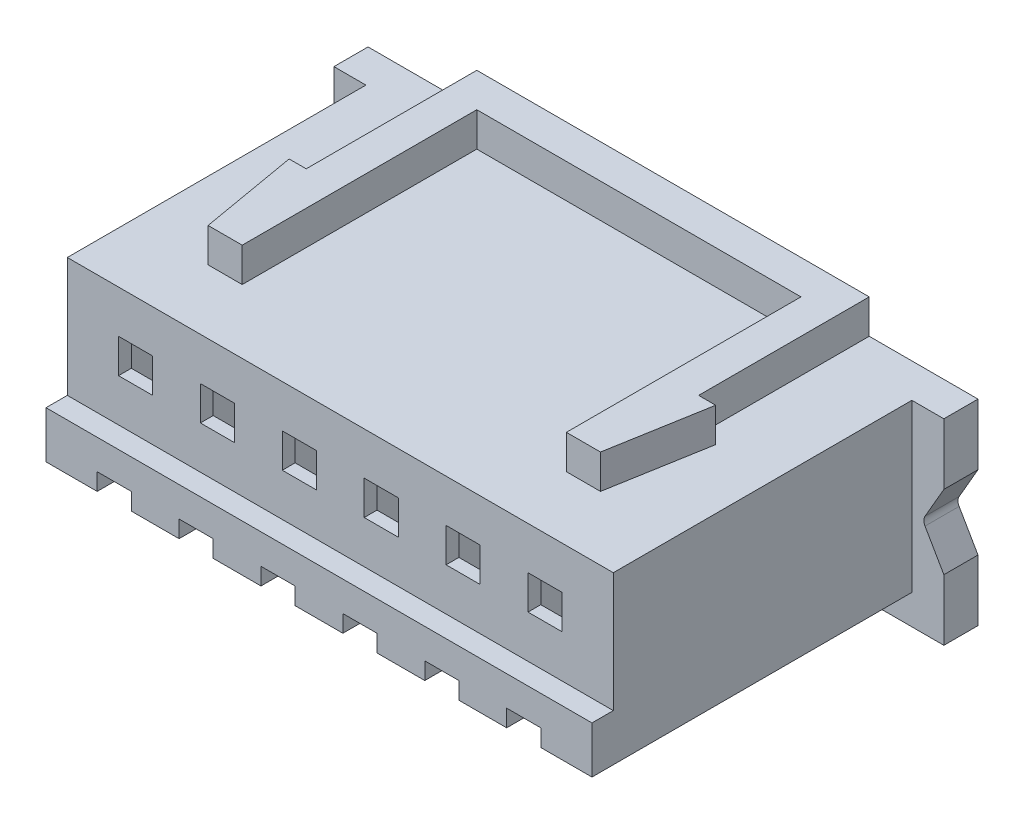
from build123d import *

# Parameters (mm, degrees)
SKETCH1_W           = 12.8
SKETCH1_H           = 4.3
BOSS_EXTRUDE1_DEPTH = 7
SKETCH2_W           = 14.3
SKETCH2_H           = 4.6
BOSS_EXTRUDE2_DEPTH = 0.8
CUT_EXTRUDE1_DEPTH  = 1
FILLET1_R           = 0.2
SKETCH4_W           = 12.8
SKETCH4_H           = 1.5
BOSS_EXTRUDE3_DEPTH = 0.5
SKETCH5_W           = 0.8
SKETCH5_H           = 0.8
CUT_EXTRUDE2_DEPTH  = 3.2
SKETCH6_W           = 0.8
SKETCH6_H           = 0.8
CUT_EXTRUDE3_DEPTH  = 10
BOSS_EXTRUDE4_DEPTH = 0.8
CUT_EXTRUDE4_DEPTH  = 7.5
CUT_EXTRUDE5_DEPTH  = 0.4
BOSS_EXTRUDE5_DEPTH = 0.1


with BuildPart() as part:
    # Sketch1 → Boss-Extrude1 (new body)
    with BuildSketch(Plane.XY):
        Rectangle(SKETCH1_W, SKETCH1_H)
    extrude(amount=BOSS_EXTRUDE1_DEPTH)

    # Sketch2 → Boss-Extrude2 (add)
    with BuildSketch(Plane(origin=(0, 0, 0), x_dir=(-1, 0, 0), z_dir=(0, 0, -1))):
        with Locations((0, -0.15)):
            Rectangle(SKETCH2_W, SKETCH2_H)
    extrude(amount=BOSS_EXTRUDE2_DEPTH)

    # Sketch3 → Cut-Extrude1 (cut)
    with BuildSketch(Plane.XY):
        Polygon((6.65, -0.15), (7.15, -1.016025404), (7.15, 0.716025404), align=None)
    extrude(amount=-CUT_EXTRUDE1_DEPTH, mode=Mode.SUBTRACT)

    # Fillet1
    fillet1_edges = [part.edges().sort_by_distance(p)[0] for p in [
        (6.65, -0.15, -0.4),
    ]]
    fillet(fillet1_edges, radius=FILLET1_R)

    # Sketch4 → Boss-Extrude3 (add)
    with BuildSketch(Plane.XY.offset(7)):
        with Locations((0, -1.4)):
            Rectangle(SKETCH4_W, SKETCH4_H)
    extrude(amount=BOSS_EXTRUDE3_DEPTH)

    # Sketch5 → Cut-Extrude2 (cut)
    with BuildSketch(Plane.XY.offset(7.5)):
        with Locations((2.88, -1.75)):
            Rectangle(SKETCH5_W, SKETCH5_H)
        with Locations((0.96, -1.75)):
            Rectangle(SKETCH5_W, SKETCH5_H)
        with Locations((-0.96, -1.75)):
            Rectangle(SKETCH5_W, SKETCH5_H)
        with Locations((4.8, -1.75)):
            Rectangle(SKETCH5_W, SKETCH5_H)
        with Locations((-2.88, -1.75)):
            Rectangle(SKETCH5_W, SKETCH5_H)
        with Locations((-4.8, -1.75)):
            Rectangle(SKETCH5_W, SKETCH5_H)
    extrude(amount=-CUT_EXTRUDE2_DEPTH, mode=Mode.SUBTRACT)

    # Sketch6 → Cut-Extrude3 (cut)
    with BuildSketch(Plane.XY.offset(7)):
        with Locations((-4.8, 0.75)):
            Rectangle(SKETCH6_W, SKETCH6_H)
        with Locations((-2.88, 0.75)):
            Rectangle(SKETCH6_W, SKETCH6_H)
        with Locations((-0.96, 0.75)):
            Rectangle(SKETCH6_W, SKETCH6_H)
        with Locations((0.96, 0.75)):
            Rectangle(SKETCH6_W, SKETCH6_H)
        with Locations((2.88, 0.75)):
            Rectangle(SKETCH6_W, SKETCH6_H)
        with Locations((4.8, 0.75)):
            Rectangle(SKETCH6_W, SKETCH6_H)
    extrude(amount=-CUT_EXTRUDE3_DEPTH, mode=Mode.SUBTRACT)

    # Sketch7 → Boss-Extrude4 (add)
    with BuildSketch(Plane(origin=(0, 2.15, 0), x_dir=(1, 0, 0), z_dir=(0, 1, 0))):
        Polygon((-4.6, -5.5), (-5, -3.2), (-4.6, -3.2), (-4.6, 0.8), (4.6, 0.8), (4.6, -3.2), (5, -3.2), (4.6, -5.5), (3.8, -5.5), (3.8, 0), (-3.8, 0), (-3.8, -5.5), align=None)
    extrude(amount=BOSS_EXTRUDE4_DEPTH)

    # Sketch8 → Cut-Extrude4 (cut)
    with BuildSketch(Plane(origin=(0, 0, -0.8), x_dir=(-1, 0, 0), z_dir=(0, 0, -1))):
        Polygon((5.8, 1.85), (3.88, 1.85), (3.88, -0.95), (4.4, -0.95), (4.4, -1.35), (5.2, -1.35), (5.2, -0.95), (5.8, -0.95), align=None)
        Polygon((3.8, 1.85), (3.8, -0.95), (3.28, -0.95), (3.28, -1.35), (2.48, -1.35), (2.48, -0.95), (1.96, -0.95), (1.96, 1.85), align=None)
        Polygon((1.88, 1.85), (1.88, -0.95), (1.36, -0.95), (1.36, -1.35), (0.56, -1.35), (0.56, -0.95), (0.04, -0.95), (0.04, 1.85), align=None)
        Polygon((-0.04, 1.85), (-0.04, -0.95), (-0.56, -0.95), (-0.56, -1.35), (-1.36, -1.35), (-1.36, -0.95), (-1.88, -0.95), (-1.88, 1.85), align=None)
        Polygon((-1.96, 1.85), (-1.96, -0.95), (-2.48, -0.95), (-2.48, -1.35), (-3.28, -1.35), (-3.28, -0.95), (-3.8, -0.95), (-3.8, 1.85), align=None)
        Polygon((-3.88, 1.85), (-3.88, -0.95), (-4.4, -0.95), (-4.4, -1.35), (-5.2, -1.35), (-5.2, -0.95), (-5.8, -0.95), (-5.8, 1.85), align=None)
    extrude(amount=-CUT_EXTRUDE4_DEPTH, mode=Mode.SUBTRACT)

    # Sketch9 → Cut-Extrude5 (cut)
    with BuildSketch(Plane.XZ.offset(2.15)):
        Polygon((-5.2, 7.5), (-6.4, 7.5), (-6.4, 0), (6.4, 0), (6.4, 7.5), (5.2, 7.5), (5.2, 4.3), (4.4, 4.3), (4.4, 7.5), (3.28, 7.5), (3.28, 4.3), (2.48, 4.3), (2.48, 7.5), (1.36, 7.5), (1.36, 4.3), (0.56, 4.3), (0.56, 7.5), (-0.56, 7.5), (-0.56, 4.3), (-1.36, 4.3), (-1.36, 7.5), (-2.48, 7.5), (-2.48, 4.3), (-3.28, 4.3), (-3.28, 7.5), (-4.4, 7.5), (-4.4, 4.3), (-5.2, 4.3), align=None)
    extrude(amount=-CUT_EXTRUDE5_DEPTH, mode=Mode.SUBTRACT)

    # Sketch10 → Boss-Extrude5 (add)
    with BuildSketch(Plane(origin=(0, 0, -0.8), x_dir=(-1, 0, 0), z_dir=(0, 0, -1))):
        Polygon((-4.875207769, -1.46566718), (-4.782759852, -1.46566718), (-4.782759852, -1.96566718), (-4.827631647, -1.96566718), (-4.827631647, -1.516949231), (-4.904554724, -1.516949231), align=None)
        with BuildLine():
            Line((-2.994298313, -1.619513334), (-3.039170108, -1.619513334))
            add(Edge.make_bspline(
                [(-3.039170108, -1.619513334), (-3.038877658, -1.61356035), (-3.038303293, -1.601868848), (-3.035613537, -1.584822575), (-3.031764841, -1.568529033), (-3.026323204, -1.553119045), (-3.019565165, -1.538456358), (-3.011460875, -1.524599213), (-3.001861754, -1.511600472), (-2.990975077, -1.499580637), (-2.979150986, -1.488553841), (-2.966392995, -1.479031664), (-2.952986562, -1.470986282), (-2.938972362, -1.464260391), (-2.924192282, -1.459211841), (-2.908780445, -1.455465893), (-2.89266914, -1.453212129), (-2.881691994, -1.452969874), (-2.876109211, -1.452846667)],
                knots=[0, 0, 0, 0, 1.7869e-05, 3.5094e-05, 5.1686e-05, 6.8032e-05, 8.4031e-05, 0.000100058, 0.000116104, 0.000132416, 0.000148647, 0.000164532, 0.000180078, 0.00019549, 0.000211074, 0.000226841, 0.000243017, 0.000259759, 0.000259759, 0.000259759, 0.000259759], degree=3))
            add(Edge.make_bspline(
                [(-2.876109211, -1.452846667), (-2.870626629, -1.452975018), (-2.859853551, -1.453227223), (-2.844130406, -1.455393084), (-2.829162221, -1.458785312), (-2.814978255, -1.463544657), (-2.801691674, -1.469942432), (-2.789202667, -1.477627795), (-2.777362552, -1.486516342), (-2.76670444, -1.496981173), (-2.756917571, -1.508152942), (-2.748474392, -1.520079785), (-2.74124394, -1.532398255), (-2.735217129, -1.545202284), (-2.730780537, -1.558612431), (-2.727412222, -1.572433459), (-2.725508306, -1.586808432), (-2.725216102, -1.59653794), (-2.725067544, -1.601484488)],
                knots=[0, 0, 0, 0, 1.6441e-05, 3.2306e-05, 4.7516e-05, 6.2435e-05, 7.7085e-05, 9.1652e-05, 0.000106376, 0.000121393, 0.000136374, 0.000150882, 0.000165157, 0.000179183, 0.000193247, 0.000207458, 0.000221808, 0.000236648, 0.000236648, 0.000236648, 0.000236648], degree=3))
            add(Edge.make_bspline(
                [(-2.725067544, -1.601484488), (-2.725309439, -1.608448464), (-2.725788983, -1.622254209), (-2.729891037, -1.642542046), (-2.736297682, -1.662198249), (-2.74401159, -1.678017864), (-2.751793367, -1.690765506), (-2.758805868, -1.701261035), (-2.767015127, -1.712561816), (-2.776540627, -1.724630007), (-2.787185323, -1.737560137), (-2.799045632, -1.751344393), (-2.812206129, -1.76584036), (-2.821443058, -1.77574116), (-2.826229403, -1.780871507)],
                knots=[0, 0, 0, 0, 2.0874e-05, 4.1382e-05, 6.1843e-05, 8.2763e-05, 9.3997e-05, 0.000106637, 0.000120621, 0.000135888, 0.000152753, 0.000170863, 0.000190435, 0.000211484, 0.000211484, 0.000211484, 0.000211484], degree=3))
            Line((-2.826229403, -1.780871507), (-2.951329563, -1.914385129))
            Line((-2.951329563, -1.914385129), (-2.718657288, -1.914385129))
            Line((-2.718657288, -1.914385129), (-2.718657288, -1.96566718))
            Line((-2.718657288, -1.96566718), (-3.058400877, -1.96566718))
            Line((-3.058400877, -1.96566718), (-2.864490621, -1.75873609))
            add(Edge.make_bspline(
                [(-2.864490621, -1.75873609), (-2.859769494, -1.753807761), (-2.850701176, -1.744341448), (-2.837875094, -1.730521026), (-2.826355238, -1.717699663), (-2.816067039, -1.705901584), (-2.807233681, -1.694954217), (-2.799394791, -1.685212117), (-2.793113992, -1.676247195), (-2.786297507, -1.665855679), (-2.77969551, -1.653168205), (-2.774022316, -1.637663392), (-2.770563052, -1.621702356), (-2.770148076, -1.610916351), (-2.769939339, -1.605490898)],
                knots=[0, 0, 0, 0, 2.0474e-05, 3.9327e-05, 5.6561e-05, 7.2184e-05, 8.6278e-05, 9.8762e-05, 0.000109683, 0.000119101, 0.000136035, 0.000152448, 0.000168517, 0.00018478, 0.00018478, 0.00018478, 0.00018478], degree=3))
            add(Edge.make_bspline(
                [(-2.769939339, -1.605490898), (-2.770030159, -1.60207927), (-2.770209149, -1.595355605), (-2.77178882, -1.58549764), (-2.774176035, -1.575988381), (-2.777596786, -1.566798578), (-2.782112035, -1.558020628), (-2.787608232, -1.549643845), (-2.79394967, -1.541545421), (-2.801285565, -1.533952093), (-2.809344354, -1.526997635), (-2.817857818, -1.520837051), (-2.826864976, -1.515688607), (-2.83632785, -1.511468107), (-2.84622006, -1.508157339), (-2.856560738, -1.505863256), (-2.867321312, -1.504422901), (-2.874668954, -1.504228019), (-2.878412897, -1.504128718)],
                knots=[0, 0, 0, 0, 1.0229e-05, 2.0159e-05, 2.9876e-05, 3.9606e-05, 4.9505e-05, 5.9423e-05, 6.9622e-05, 8.0319e-05, 9.1042e-05, 0.000101521, 0.000111795, 0.000122107, 0.000132559, 0.000143032, 0.000153841, 0.00016507, 0.00016507, 0.00016507, 0.00016507], degree=3))
            add(Edge.make_bspline(
                [(-2.878412897, -1.504128718), (-2.882323016, -1.504230866), (-2.890001844, -1.504431467), (-2.901275991, -1.505834704), (-2.912031102, -1.508255539), (-2.922294231, -1.511566492), (-2.932082744, -1.515774856), (-2.941349036, -1.521016534), (-2.950072306, -1.527271319), (-2.958268952, -1.534362827), (-2.965820949, -1.542258199), (-2.972456217, -1.551059622), (-2.978253933, -1.560606395), (-2.983312395, -1.57087276), (-2.987420351, -1.581951871), (-2.990559372, -1.593804401), (-2.993043207, -1.606378884), (-2.993872996, -1.615062467), (-2.994298313, -1.619513334)],
                knots=[0, 0, 0, 0, 1.1729e-05, 2.3035e-05, 3.4018e-05, 4.4756e-05, 5.5343e-05, 6.5928e-05, 7.6628e-05, 8.7492e-05, 9.8403e-05, 0.00010934, 0.000120489, 0.000131867, 0.000143625, 0.00015587, 0.000168619, 0.000182025, 0.000182025, 0.000182025, 0.000182025], degree=3))
        make_face()
        with BuildLine():
            Line((-1.07122139, -1.581051795), (-1.116093185, -1.581051795))
            add(Edge.make_bspline(
                [(-1.116093185, -1.581051795), (-1.114877535, -1.576018583), (-1.112501039, -1.566179066), (-1.107544242, -1.552120886), (-1.102144349, -1.538817525), (-1.095660191, -1.526518086), (-1.088587512, -1.514975386), (-1.080484266, -1.504451225), (-1.071724305, -1.494677944), (-1.062035027, -1.486004625), (-1.05187379, -1.478150663), (-1.041097415, -1.471454227), (-1.029922716, -1.465693633), (-1.018272269, -1.460947886), (-1.006111387, -1.457372811), (-0.993550012, -1.454778982), (-0.980555227, -1.453094537), (-0.971734142, -1.452930142), (-0.967255044, -1.452846667)],
                knots=[0, 0, 0, 0, 1.5524e-05, 3.0347e-05, 4.467e-05, 5.8558e-05, 7.201e-05, 8.5231e-05, 9.8349e-05, 0.000111325, 0.000124187, 0.000136831, 0.000149329, 0.000161865, 0.00017451, 0.000187298, 0.000200318, 0.000213748, 0.000213748, 0.000213748, 0.000213748], degree=3))
            add(Edge.make_bspline(
                [(-0.967255044, -1.452846667), (-0.960728938, -1.4530437), (-0.947819079, -1.453433468), (-0.92885293, -1.456992673), (-0.910563384, -1.462624835), (-0.893150635, -1.470406796), (-0.876976573, -1.480004984), (-0.862585689, -1.491428517), (-0.850173045, -1.504456989), (-0.839759562, -1.518847355), (-0.831605991, -1.534226714), (-0.825593652, -1.550055308), (-0.821933412, -1.566295589), (-0.821459046, -1.577260915), (-0.82122139, -1.58275452)],
                knots=[0, 0, 0, 0, 1.9562e-05, 3.8698e-05, 5.7675e-05, 7.6865e-05, 9.5777e-05, 0.000113954, 0.000131807, 0.000149598, 0.000167073, 0.000183872, 0.000200276, 0.000216747, 0.000216747, 0.000216747, 0.000216747], degree=3))
            add(Edge.make_bspline(
                [(-0.82122139, -1.58275452), (-0.821387618, -1.588041205), (-0.821712899, -1.598386427), (-0.824474857, -1.613489498), (-0.829122894, -1.627724012), (-0.835561432, -1.641149892), (-0.843895939, -1.653682012), (-0.853992038, -1.665348568), (-0.86592099, -1.676201305), (-0.874960838, -1.682418373), (-0.87961482, -1.685619103)],
                knots=[0, 0, 0, 0, 1.5851e-05, 3.1018e-05, 4.5873e-05, 6.0656e-05, 7.5546e-05, 9.0886e-05, 0.000106841, 0.00012377, 0.00012377, 0.00012377, 0.00012377], degree=3))
            add(Edge.make_bspline(
                [(-0.87961482, -1.685619103), (-0.874295998, -1.688187413), (-0.863757873, -1.693275979), (-0.849393511, -1.703255373), (-0.836353815, -1.714777708), (-0.829081855, -1.723769516), (-0.825428121, -1.728287372)],
                knots=[0, 0, 0, 0, 1.7695e-05, 3.5058e-05, 5.2293e-05, 6.9697e-05, 6.9697e-05, 6.9697e-05, 6.9697e-05], degree=3))
            add(Edge.make_bspline(
                [(-0.825428121, -1.728287372), (-0.823022215, -1.731581337), (-0.818249801, -1.738115325), (-0.812359011, -1.748620529), (-0.807014852, -1.75924217), (-0.802850535, -1.770264942), (-0.799625696, -1.781561087), (-0.797320549, -1.793150001), (-0.795888529, -1.805041147), (-0.79568345, -1.813085787), (-0.795580365, -1.81712952)],
                knots=[0, 0, 0, 0, 1.2226e-05, 2.4252e-05, 3.6078e-05, 4.7871e-05, 5.9538e-05, 7.1285e-05, 8.3286e-05, 9.5416e-05, 9.5416e-05, 9.5416e-05, 9.5416e-05], degree=3))
            add(Edge.make_bspline(
                [(-0.795580365, -1.81712952), (-0.795836724, -1.824130909), (-0.796348235, -1.838100737), (-0.800920246, -1.858739983), (-0.808007852, -1.878915055), (-0.818073128, -1.898211461), (-0.830339915, -1.916265801), (-0.844933819, -1.932419559), (-0.86168902, -1.946305074), (-0.880375541, -1.957906535), (-0.900620845, -1.967180524), (-0.922274501, -1.973617302), (-0.945024509, -1.977809587), (-0.960625552, -1.97825914), (-0.968557127, -1.978487693)],
                knots=[0, 0, 0, 0, 2.098e-05, 4.1862e-05, 6.3119e-05, 8.498e-05, 0.000106955, 0.000128441, 0.000150062, 0.000172018, 0.00019425, 0.000216652, 0.00023964, 0.000263413, 0.000263413, 0.000263413, 0.000263413], degree=3))
            add(Edge.make_bspline(
                [(-0.968557127, -1.978487693), (-0.973902742, -1.978363662), (-0.984421128, -1.978119612), (-0.999884485, -1.97645124), (-1.014644728, -1.973404097), (-1.028721813, -1.969303624), (-1.042128247, -1.964104804), (-1.054823119, -1.957630704), (-1.066884533, -1.950014776), (-1.078198669, -1.94116712), (-1.088764178, -1.931269786), (-1.098300282, -1.92014707), (-1.106965966, -1.908004584), (-1.1145292, -1.89470129), (-1.121334479, -1.880409111), (-1.126931759, -1.864945039), (-1.131858269, -1.848447322), (-1.134148764, -1.836950502), (-1.135323954, -1.831051795)],
                knots=[0, 0, 0, 0, 1.6037e-05, 3.1555e-05, 4.6582e-05, 6.1194e-05, 7.5497e-05, 8.9652e-05, 0.000103879, 0.000118224, 0.000132679, 0.000147236, 0.000162105, 0.000177361, 0.000193087, 0.000209535, 0.00022665, 0.000244684, 0.000244684, 0.000244684, 0.000244684], degree=3))
            Line((-1.135323954, -1.831051795), (-1.09045216, -1.831051795))
            add(Edge.make_bspline(
                [(-1.09045216, -1.831051795), (-1.089283118, -1.834901654), (-1.08700923, -1.842389965), (-1.083138616, -1.853167151), (-1.078728863, -1.863046873), (-1.073998212, -1.872101605), (-1.069029863, -1.880420519), (-1.063470588, -1.887783644), (-1.057732138, -1.894514387), (-1.053406516, -1.898306474), (-1.051289499, -1.900162372)],
                knots=[0, 0, 0, 0, 1.207e-05, 2.3476e-05, 3.4328e-05, 4.4497e-05, 5.4117e-05, 6.3352e-05, 7.2152e-05, 8.0588e-05, 8.0588e-05, 8.0588e-05, 8.0588e-05], degree=3))
            add(Edge.make_bspline(
                [(-1.051289499, -1.900162372), (-1.048489988, -1.902320706), (-1.042899608, -1.90663071), (-1.033789861, -1.912130943), (-1.024209163, -1.916896804), (-1.013949923, -1.920537332), (-1.003233528, -1.923619855), (-0.991886761, -1.925637072), (-0.98000973, -1.927021096), (-0.97190005, -1.927143229), (-0.967755845, -1.927205642)],
                knots=[0, 0, 0, 0, 1.0597e-05, 2.1162e-05, 3.1867e-05, 4.2641e-05, 5.3771e-05, 6.5283e-05, 7.7174e-05, 8.96e-05, 8.96e-05, 8.96e-05, 8.96e-05], degree=3))
            add(Edge.make_bspline(
                [(-0.967755845, -1.927205642), (-0.963076774, -1.927117655), (-0.953927253, -1.926945605), (-0.940576558, -1.925363361), (-0.927875495, -1.923059017), (-0.915965077, -1.919500019), (-0.90468929, -1.915102755), (-0.894206197, -1.909581554), (-0.884378182, -1.903103736), (-0.875331124, -1.895740999), (-0.867196051, -1.887680786), (-0.860033264, -1.879250347), (-0.853944026, -1.870485229), (-0.849032087, -1.861336926), (-0.845153437, -1.851843321), (-0.842512979, -1.841977774), (-0.840677049, -1.831821022), (-0.840527533, -1.824916884), (-0.84045216, -1.821436411)],
                knots=[0, 0, 0, 0, 1.4031e-05, 2.7437e-05, 4.0284e-05, 5.2708e-05, 6.4668e-05, 7.654e-05, 8.818e-05, 9.9927e-05, 0.000111472, 0.000122488, 0.000133073, 0.000143425, 0.000153581, 0.000163762, 0.000174021, 0.000184449, 0.000184449, 0.000184449, 0.000184449], degree=3))
            add(Edge.make_bspline(
                [(-0.84045216, -1.821436411), (-0.840670774, -1.816777648), (-0.841106915, -1.807483304), (-0.844436712, -1.793809365), (-0.849913693, -1.780634592), (-0.857581195, -1.768183765), (-0.86691487, -1.75664435), (-0.877824142, -1.746348424), (-0.890399604, -1.737852697), (-0.901973871, -1.731982889), (-0.912226036, -1.727977592), (-0.920999662, -1.72530974), (-0.930822034, -1.723050646), (-0.94157437, -1.720948893), (-0.953337686, -1.719160129), (-0.966099177, -1.717668441), (-0.979861429, -1.716474864), (-0.989388739, -1.71594185), (-0.994298313, -1.71566718)],
                knots=[0, 0, 0, 0, 1.3966e-05, 2.7862e-05, 4.1962e-05, 5.6614e-05, 7.1569e-05, 8.6379e-05, 0.000101437, 0.000116935, 0.000125212, 0.000134432, 0.000144417, 0.000155437, 0.000167294, 0.000180102, 0.000193977, 0.000208728, 0.000208728, 0.000208728, 0.000208728], degree=3))
            Line((-0.994298313, -1.71566718), (-0.994298313, -1.664385129))
            add(Edge.make_bspline(
                [(-0.994298313, -1.664385129), (-0.988112433, -1.664280157), (-0.975995812, -1.664074543), (-0.958296625, -1.661587684), (-0.941371866, -1.658147594), (-0.925596618, -1.652878281), (-0.91121823, -1.646758239), (-0.898744001, -1.639636494), (-0.888348694, -1.631720102), (-0.880082827, -1.622886872), (-0.873864366, -1.613413293), (-0.86931768, -1.603539485), (-0.866631919, -1.593178905), (-0.866273396, -1.586108238), (-0.866093185, -1.582554199)],
                knots=[0, 0, 0, 0, 1.8543e-05, 3.6321e-05, 5.353e-05, 7.0285e-05, 8.612e-05, 0.000100345, 0.000113267, 0.000125173, 0.000136452, 0.00014712, 0.000157663, 0.000168319, 0.000168319, 0.000168319, 0.000168319], degree=3))
            add(Edge.make_bspline(
                [(-0.866093185, -1.582554199), (-0.866152387, -1.579943093), (-0.866270165, -1.57474842), (-0.867755491, -1.567159125), (-0.869987497, -1.559801847), (-0.873056029, -1.552707874), (-0.877163201, -1.545926406), (-0.882078342, -1.539399628), (-0.887930927, -1.533164802), (-0.89463742, -1.527353328), (-0.901839106, -1.521814866), (-0.909731931, -1.517112917), (-0.918077913, -1.513092194), (-0.926886293, -1.509776551), (-0.936185654, -1.507282367), (-0.945932305, -1.505491533), (-0.956144831, -1.504371868), (-0.963112222, -1.504210665), (-0.966654083, -1.504128718)],
                knots=[0, 0, 0, 0, 7.823e-06, 1.5563e-05, 2.3104e-05, 3.0863e-05, 3.8679e-05, 4.6832e-05, 5.5336e-05, 6.4278e-05, 7.3432e-05, 8.2553e-05, 9.1782e-05, 0.000101195, 0.000110744, 0.000120626, 0.000130901, 0.000141526, 0.000141526, 0.000141526, 0.000141526], degree=3))
            add(Edge.make_bspline(
                [(-0.966654083, -1.504128718), (-0.972347178, -1.504327484), (-0.983467118, -1.504715721), (-0.99949782, -1.508116151), (-1.014400582, -1.513541592), (-1.02579182, -1.520017737), (-1.034203616, -1.526410656), (-1.040214608, -1.531993855), (-1.046117538, -1.538198544), (-1.051524063, -1.545406883), (-1.056991774, -1.55313071), (-1.061969568, -1.561762665), (-1.066806667, -1.571077578), (-1.069721317, -1.577662669), (-1.07122139, -1.581051795)],
                knots=[0, 0, 0, 0, 1.7063e-05, 3.3328e-05, 4.8919e-05, 6.4486e-05, 7.2419e-05, 8.0571e-05, 8.9075e-05, 9.807e-05, 0.000107572, 0.00011745, 0.000127932, 0.000139048, 0.000139048, 0.000139048, 0.000139048], degree=3))
        make_face()
        Polygon((1.060689667, -1.452846667), (1.069804251, -1.452846667), (1.069804251, -1.799000513), (1.127496558, -1.799000513), (1.127496558, -1.850282565), (1.069804251, -1.850282565), (1.069804251, -1.96566718), (1.024932456, -1.96566718), (1.024932456, -1.850282565), (0.787752969, -1.850282565), align=None)
        Polygon((1.024932456, -1.799000513), (1.024932456, -1.581853077), (0.875893994, -1.799000513), align=None, mode=Mode.SUBTRACT)
        with BuildLine():
            Line((3.024932456, -1.46566718), (3.024932456, -1.516949231))
            Line((3.024932456, -1.516949231), (2.85486034, -1.516949231))
            Line((2.85486034, -1.516949231), (2.827917231, -1.648459648))
            add(Edge.make_bspline(
                [(2.827917231, -1.648459648), (2.833210928, -1.646998181), (2.843466627, -1.644166819), (2.85860375, -1.641023137), (2.872974065, -1.639128074), (2.882299118, -1.638869315), (2.886811462, -1.638744103)],
                knots=[0, 0, 0, 0, 1.6472e-05, 3.1911e-05, 4.6347e-05, 5.9882e-05, 5.9882e-05, 5.9882e-05, 5.9882e-05], degree=3))
            add(Edge.make_bspline(
                [(2.886811462, -1.638744103), (2.892394854, -1.638864951), (2.903373196, -1.639102568), (2.919435903, -1.641384261), (2.934769173, -1.644975677), (2.94934094, -1.649992895), (2.963178162, -1.656408571), (2.976153528, -1.664422848), (2.988461801, -1.673784753), (2.999882172, -1.684548326), (3.010242787, -1.696394271), (3.019352214, -1.70913111), (3.027089727, -1.722635062), (3.033312692, -1.737035149), (3.038281883, -1.75217217), (3.041589311, -1.768205396), (3.043791698, -1.784983699), (3.044037753, -1.796455781), (3.044163225, -1.802305802)],
                knots=[0, 0, 0, 0, 1.6741e-05, 3.2918e-05, 4.8563e-05, 6.3926e-05, 7.9071e-05, 9.4222e-05, 0.000109587, 0.000125389, 0.000141218, 0.000156727, 0.000172294, 0.000187813, 0.000203714, 0.000219999, 0.000236858, 0.0002544, 0.0002544, 0.0002544, 0.0002544], degree=3))
            add(Edge.make_bspline(
                [(3.044163225, -1.802305802), (3.044068214, -1.806380405), (3.043879477, -1.814474546), (3.042919679, -1.826495146), (3.041071719, -1.838261265), (3.038590616, -1.849774464), (3.03537027, -1.861012945), (3.031471834, -1.872008878), (3.026700973, -1.882693822), (3.021467919, -1.893168878), (3.015575565, -1.903197236), (3.009035779, -1.912575663), (3.002126423, -1.921444846), (2.994691939, -1.929709665), (2.986663225, -1.937315811), (2.978137516, -1.944308422), (2.969182842, -1.950805755), (2.959660664, -1.956544069), (2.949783167, -1.961824491), (2.939407707, -1.966156425), (2.928770464, -1.970029358), (2.917718339, -1.973116433), (2.906276366, -1.975535369), (2.894425684, -1.977178312), (2.882228445, -1.978374946), (2.873960586, -1.978449854), (2.869784219, -1.978487693)],
                knots=[0, 0, 0, 0, 1.2226e-05, 2.4287e-05, 3.6144e-05, 4.7931e-05, 5.9598e-05, 7.1193e-05, 8.2899e-05, 9.4679e-05, 0.000106309, 0.000117755, 0.000128956, 0.000140019, 0.000151071, 0.0001621, 0.00017308, 0.000184228, 0.000195429, 0.000206647, 0.000217926, 0.000229373, 0.000241041, 0.000252982, 0.000265251, 0.000277775, 0.000277775, 0.000277775, 0.000277775], degree=3))
            add(Edge.make_bspline(
                [(2.869784219, -1.978487693), (2.864802193, -1.978389002), (2.855000646, -1.978194839), (2.840640565, -1.976163626), (2.826824192, -1.973254495), (2.813662749, -1.968877885), (2.801038283, -1.963393986), (2.789120752, -1.956463105), (2.777605641, -1.948608947), (2.766961064, -1.939340325), (2.75708162, -1.929209513), (2.748237833, -1.918215565), (2.740361607, -1.90653993), (2.733579072, -1.894125908), (2.727793641, -1.881006118), (2.723248642, -1.867131403), (2.719580306, -1.85257426), (2.718028389, -1.84255233), (2.717240148, -1.837462052)],
                knots=[0, 0, 0, 0, 1.4936e-05, 2.9385e-05, 4.3432e-05, 5.7242e-05, 7.092e-05, 8.4648e-05, 9.854e-05, 0.000112674, 0.000126911, 0.000140942, 0.000154943, 0.000169108, 0.000183326, 0.000197895, 0.00021286, 0.000228305, 0.000228305, 0.000228305, 0.000228305], degree=3))
            Line((2.717240148, -1.837462052), (2.762111943, -1.837462052))
            add(Edge.make_bspline(
                [(2.762111943, -1.837462052), (2.763216023, -1.842230116), (2.765338125, -1.851394601), (2.769996089, -1.864270507), (2.775691214, -1.875744682), (2.782463264, -1.885968908), (2.79054184, -1.894884479), (2.79976033, -1.902829774), (2.810095719, -1.90999765), (2.821580466, -1.915972331), (2.83369662, -1.921067867), (2.84637765, -1.924460966), (2.859278271, -1.926846808), (2.868003752, -1.927085631), (2.872388385, -1.927205642)],
                knots=[0, 0, 0, 0, 1.4673e-05, 2.8202e-05, 4.0968e-05, 5.3024e-05, 6.4869e-05, 7.6939e-05, 8.9469e-05, 0.000102507, 0.000115713, 0.000128811, 0.00014182, 0.00015496, 0.00015496, 0.00015496, 0.00015496], degree=3))
            add(Edge.make_bspline(
                [(2.872388385, -1.927205642), (2.876668163, -1.927088388), (2.885095081, -1.926857514), (2.897496707, -1.925080512), (2.909469975, -1.922343716), (2.92089674, -1.918248022), (2.93197696, -1.913270205), (2.942430356, -1.906882337), (2.952559338, -1.899530906), (2.962049072, -1.891108531), (2.970740422, -1.881827146), (2.978419868, -1.871901804), (2.984816569, -1.861313683), (2.990207156, -1.850246089), (2.994300485, -1.838577724), (2.997220625, -1.826363271), (2.998935348, -1.813572559), (2.999171231, -1.804848372), (2.99929143, -1.800402757)],
                knots=[0, 0, 0, 0, 1.2835e-05, 2.5271e-05, 3.7516e-05, 4.9617e-05, 6.1628e-05, 7.3893e-05, 8.6294e-05, 9.9136e-05, 0.000111892, 0.000124393, 0.000136709, 0.000148939, 0.000161262, 0.000173724, 0.000186558, 0.000199893, 0.000199893, 0.000199893, 0.000199893], degree=3))
            add(Edge.make_bspline(
                [(2.99929143, -1.800402757), (2.999197362, -1.796391935), (2.999013236, -1.788541323), (2.997508869, -1.777055722), (2.994892158, -1.766188144), (2.991260176, -1.755886111), (2.986648817, -1.746139905), (2.98101363, -1.736939468), (2.974248859, -1.728406063), (2.966521446, -1.720535698), (2.958056012, -1.713272144), (2.948706906, -1.707080132), (2.938669773, -1.701871001), (2.928065545, -1.697375573), (2.916641988, -1.694146895), (2.904625326, -1.691722911), (2.891885796, -1.690320716), (2.883175698, -1.690126161), (2.878698481, -1.690026154)],
                knots=[0, 0, 0, 0, 1.203e-05, 2.3546e-05, 3.4673e-05, 4.5507e-05, 5.6259e-05, 6.6962e-05, 7.7802e-05, 8.8851e-05, 0.000100009, 0.000111204, 0.000122404, 0.0001339, 0.000145691, 0.000157948, 0.000170646, 0.000184077, 0.000184077, 0.000184077, 0.000184077], degree=3))
            add(Edge.make_bspline(
                [(2.878698481, -1.690026154), (2.87482292, -1.690109096), (2.866820869, -1.690280349), (2.85454618, -1.691541277), (2.841647362, -1.693575462), (2.828173863, -1.696373498), (2.814085219, -1.70003508), (2.799411162, -1.704422866), (2.784120838, -1.709668866), (2.773818306, -1.713630611), (2.768522199, -1.71566718)],
                knots=[0, 0, 0, 0, 1.1625e-05, 2.4004e-05, 3.698e-05, 5.0789e-05, 6.5268e-05, 8.0637e-05, 9.6727e-05, 0.000113749, 0.000113749, 0.000113749, 0.000113749], degree=3))
            Line((2.768522199, -1.71566718), (2.819804251, -1.46566718))
            Line((2.819804251, -1.46566718), (3.024932456, -1.46566718))
        make_face()
        with BuildLine():
            Line((4.864676046, -1.452846667), (4.899231334, -1.479990097))
            Line((4.899231334, -1.479990097), (4.767119956, -1.682013334))
            add(Edge.make_bspline(
                [(4.767119956, -1.682013334), (4.77591571, -1.680611354), (4.793072822, -1.677876633), (4.810439379, -1.677425498), (4.818902808, -1.677205642)],
                knots=[0, 0, 0, 0, 2.6687e-05, 5.2056e-05, 5.2056e-05, 5.2056e-05, 5.2056e-05], degree=3))
            add(Edge.make_bspline(
                [(4.818902808, -1.677205642), (4.823984594, -1.677342229), (4.833987937, -1.677611097), (4.848674623, -1.679680219), (4.862787328, -1.682940949), (4.876267558, -1.687694128), (4.889163698, -1.693765893), (4.901549755, -1.701042875), (4.913192899, -1.709900829), (4.924243068, -1.719795823), (4.93427551, -1.730755392), (4.943157804, -1.742384154), (4.950618774, -1.754669995), (4.956672191, -1.76760669), (4.961372888, -1.781174298), (4.964799695, -1.795355461), (4.966825351, -1.810159957), (4.967100421, -1.820228268), (4.967240148, -1.825342661)],
                knots=[0, 0, 0, 0, 1.524e-05, 3e-05, 4.4407e-05, 5.863e-05, 7.2789e-05, 8.7115e-05, 0.000101639, 0.000116603, 0.00013156, 0.000146144, 0.000160436, 0.000174595, 0.000188912, 0.00020344, 0.000218299, 0.00023364, 0.00023364, 0.00023364, 0.00023364], degree=3))
            add(Edge.make_bspline(
                [(4.967240148, -1.825342661), (4.967036847, -1.832339761), (4.9666368, -1.846108399), (4.962650543, -1.866162215), (4.956456308, -1.88526686), (4.947602376, -1.903117313), (4.936604892, -1.919689108), (4.923193808, -1.934372746), (4.907844738, -1.947468466), (4.890489481, -1.958419411), (4.871811915, -1.967362704), (4.852190201, -1.97378631), (4.831814894, -1.977741092), (4.817985664, -1.978236892), (4.810990148, -1.978487693)],
                knots=[0, 0, 0, 0, 2.0968e-05, 4.126e-05, 6.1088e-05, 8.1066e-05, 0.000100845, 0.000120559, 0.000140527, 0.000161199, 0.000181942, 0.000202498, 0.000222987, 0.000243961, 0.000243961, 0.000243961, 0.000243961], degree=3))
            add(Edge.make_bspline(
                [(4.810990148, -1.978487693), (4.804262048, -1.978269378), (4.79093486, -1.977836934), (4.771330175, -1.973984657), (4.752492601, -1.967740785), (4.734554118, -1.959138745), (4.717936888, -1.948273333), (4.703070368, -1.935193008), (4.690028686, -1.92017737), (4.679175169, -1.903228749), (4.670566778, -1.885015898), (4.664111075, -1.866024876), (4.660340183, -1.846324878), (4.659813246, -1.83297043), (4.65954784, -1.826244103)],
                knots=[0, 0, 0, 0, 2.0168e-05, 3.9949e-05, 5.9682e-05, 7.9573e-05, 9.9463e-05, 0.000119052, 0.000138792, 0.000158934, 0.00017923, 0.000199089, 0.000218969, 0.000239143, 0.000239143, 0.000239143, 0.000239143], degree=3))
            add(Edge.make_bspline(
                [(4.65954784, -1.826244103), (4.659716618, -1.821094877), (4.66006123, -1.810581141), (4.662467429, -1.794657708), (4.666333828, -1.778364697), (4.670663864, -1.764542669), (4.675238951, -1.753219594), (4.679046456, -1.744090524), (4.683785599, -1.734696085), (4.688838939, -1.724714137), (4.694661349, -1.714401933), (4.700992156, -1.703587123), (4.708006392, -1.692441705), (4.712923558, -1.684878248), (4.715437264, -1.681011731)],
                knots=[0, 0, 0, 0, 1.5445e-05, 3.1537e-05, 4.8203e-05, 6.5657e-05, 7.4919e-05, 8.4835e-05, 9.5317e-05, 0.000106472, 0.000118399, 0.000130836, 0.000144064, 0.0001579, 0.0001579, 0.0001579, 0.0001579], degree=3))
            Line((4.715437264, -1.681011731), (4.864676046, -1.452846667))
        make_face()
        with BuildLine():
            add(Edge.make_bspline(
                [(4.809487744, -1.728487693), (4.805678852, -1.728598842), (4.798238979, -1.728815948), (4.787323634, -1.730076699), (4.77699317, -1.732450851), (4.767110722, -1.735474613), (4.75786105, -1.739632193), (4.74917693, -1.74468245), (4.74102478, -1.750628332), (4.733489987, -1.757385605), (4.726658607, -1.764783896), (4.720775588, -1.772708113), (4.715700959, -1.780967285), (4.711574985, -1.78963042), (4.708362117, -1.798694205), (4.706038081, -1.808116955), (4.704744688, -1.817961856), (4.704529512, -1.824637928), (4.704419635, -1.828046988)],
                knots=[0, 0, 0, 0, 1.1429e-05, 2.2325e-05, 3.2895e-05, 4.319e-05, 5.3279e-05, 6.3243e-05, 7.328e-05, 8.3494e-05, 9.356e-05, 0.000103436, 0.000113055, 0.000122598, 0.000132165, 0.000141858, 0.00015166, 0.000161889, 0.000161889, 0.000161889, 0.000161889], degree=3))
            add(Edge.make_bspline(
                [(4.704419635, -1.828046988), (4.704509116, -1.831425556), (4.704684573, -1.838050426), (4.706277761, -1.847813166), (4.708711345, -1.857208153), (4.712331401, -1.866186953), (4.716649528, -1.874886427), (4.722350289, -1.882991468), (4.728666972, -1.890994335), (4.736217534, -1.898280259), (4.744320872, -1.905059777), (4.752978187, -1.910985528), (4.762001038, -1.916054981), (4.771511241, -1.920027995), (4.781373867, -1.923288607), (4.791671089, -1.925583104), (4.802410069, -1.926880322), (4.809684631, -1.927095779), (4.813393994, -1.927205642)],
                knots=[0, 0, 0, 0, 1.0129e-05, 1.9861e-05, 2.9603e-05, 3.9182e-05, 4.8857e-05, 5.8664e-05, 6.8847e-05, 7.94e-05, 9.007e-05, 0.000100516, 0.000110828, 0.00012106, 0.000131386, 0.000141957, 0.000152653, 0.000163782, 0.000163782, 0.000163782, 0.000163782], degree=3))
            add(Edge.make_bspline(
                [(4.813393994, -1.927205642), (4.817103351, -1.92709577), (4.824377902, -1.926880297), (4.835116968, -1.925583201), (4.84541387, -1.923288252), (4.855277657, -1.920029284), (4.864783576, -1.916050197), (4.873798536, -1.911017066), (4.882373978, -1.905023335), (4.890482635, -1.898291845), (4.898001769, -1.890952866), (4.904469952, -1.883062906), (4.909996128, -1.874820921), (4.914486726, -1.866221222), (4.918066911, -1.857202724), (4.920512835, -1.847814621), (4.922102733, -1.838050045), (4.922278643, -1.831425428), (4.922368353, -1.828046988)],
                knots=[0, 0, 0, 0, 1.1129e-05, 2.1826e-05, 3.2396e-05, 4.2722e-05, 5.2954e-05, 6.3266e-05, 7.363e-05, 8.4299e-05, 9.4852e-05, 0.000105099, 0.00011485, 0.000124572, 0.00013415, 0.000143893, 0.000153625, 0.000163753, 0.000163753, 0.000163753, 0.000163753], degree=3))
            add(Edge.make_bspline(
                [(4.922368353, -1.828046988), (4.92228974, -1.82463348), (4.922135448, -1.817933876), (4.920390312, -1.808121359), (4.917969973, -1.798646329), (4.914315254, -1.789568337), (4.909567177, -1.780923204), (4.903783833, -1.772667261), (4.897093466, -1.764737212), (4.889365246, -1.757371096), (4.880952355, -1.750635799), (4.872007271, -1.744690148), (4.862648989, -1.739672295), (4.852886998, -1.735485566), (4.842609443, -1.732464212), (4.831982252, -1.730085178), (4.820869503, -1.728819175), (4.813329987, -1.728599594), (4.809487744, -1.728487693)],
                knots=[0, 0, 0, 0, 1.0229e-05, 2.0075e-05, 2.9818e-05, 3.9527e-05, 4.9343e-05, 5.9345e-05, 6.9721e-05, 8.0417e-05, 9.132e-05, 0.000102015, 0.000112591, 0.000123139, 0.000133816, 0.00014468, 0.000155775, 0.000167304, 0.000167304, 0.000167304, 0.000167304], degree=3))
        make_face(mode=Mode.SUBTRACT)
    extrude(amount=BOSS_EXTRUDE5_DEPTH)


solid = part.part
